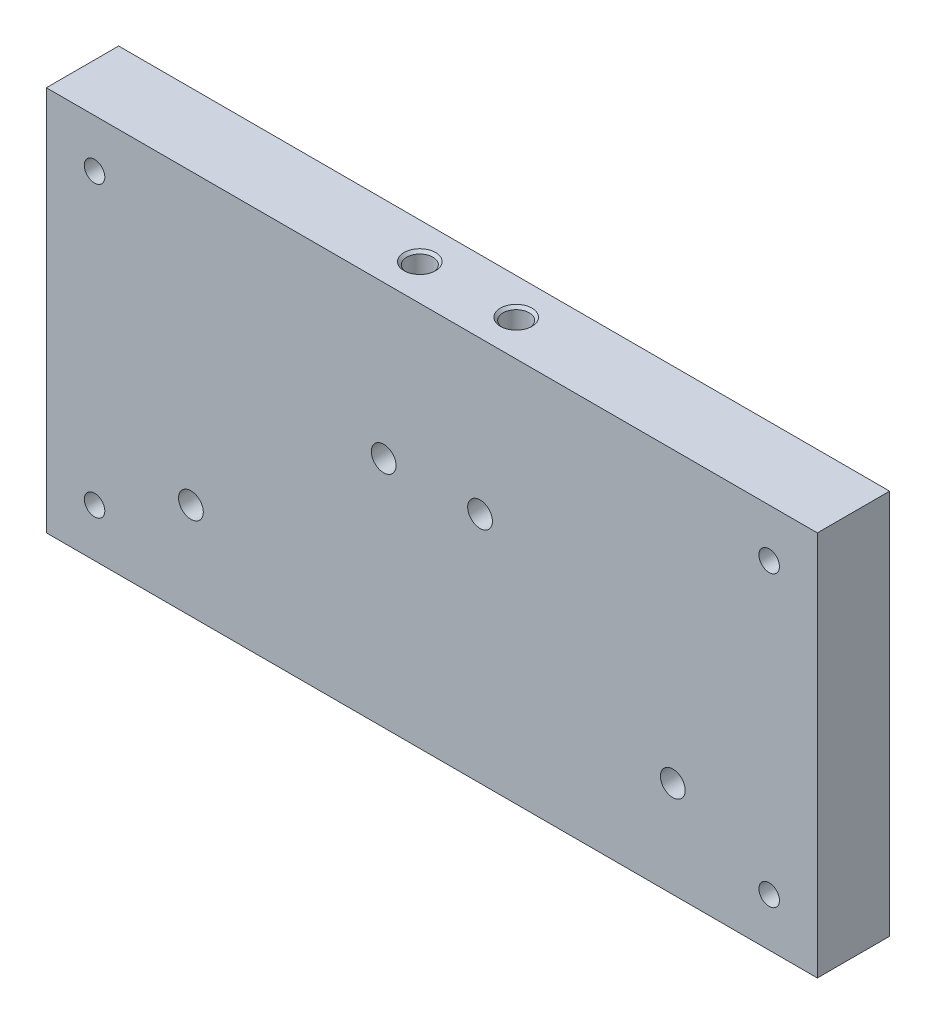
from build123d import *

# Parameters (mm, degrees)
SKETCH1_W                       = 101.6
SKETCH1_H                       = 50.8
BOSS_EXTRUDE1_DEPTH             = 9.525
F_8_32_TAPPED_HOLE1_D           = 3.4544
F_8_32_TAPPED_HOLE1_DEPTH       = 19.05
F_8_32_TAPPED_HOLE1_CSINK_D     = 4.1656
F_8_32_TAPPED_HOLE1_CSINK_ANGLE = 90
F_8_32_TAPPED_HOLE1_TIP         = 1.037806461
F_4_CLEARANCE_HOLE2_D           = 3.2639
F_4_CLEARANCE_HOLE2_DEPTH       = 25.4
F_4_CLEARANCE_HOLE2_TIP         = 0.980574487
F_6_32_TAPPED_HOLE1_D           = 2.7051
F_4_CLEARANCE_HOLE1_D           = 3.2639
F_4_CLEARANCE_HOLE1_DEPTH       = 9.525


with BuildPart() as part:
    # Sketch1 → Boss-Extrude1 (new body)
    with BuildSketch(Plane.XY):
        with Locations((-50.8, 25.4)):
            Rectangle(SKETCH1_W, SKETCH1_H)
    extrude(amount=BOSS_EXTRUDE1_DEPTH)

    # #8-32 Tapped Hole1
    with Locations(Plane(origin=(0, 50.8, 0), x_dir=(1, 0, 0), z_dir=(0, 1, 0))):
        with Locations((-44.45, -4.7625), (-57.15, -4.7625)):
            CounterSinkHole(F_8_32_TAPPED_HOLE1_D / 2, F_8_32_TAPPED_HOLE1_CSINK_D / 2, depth=F_8_32_TAPPED_HOLE1_DEPTH, counter_sink_angle=F_8_32_TAPPED_HOLE1_CSINK_ANGLE)
            with Locations((0, 0, -(F_8_32_TAPPED_HOLE1_DEPTH + F_8_32_TAPPED_HOLE1_TIP / 2))):  # 118° drill point
                Cone(0, F_8_32_TAPPED_HOLE1_D / 2, F_8_32_TAPPED_HOLE1_TIP, mode=Mode.SUBTRACT)

    # #4 Clearance Hole2
    with Locations(Plane.XY.offset(9.525)):
        with Locations((-44.45, 30.712193539), (-57.15, 30.712193539)):
            Hole(F_4_CLEARANCE_HOLE2_D / 2, depth=F_4_CLEARANCE_HOLE2_DEPTH)
            with Locations((0, 0, -(F_4_CLEARANCE_HOLE2_DEPTH + F_4_CLEARANCE_HOLE2_TIP / 2))):  # 118° drill point
                Cone(0, F_4_CLEARANCE_HOLE2_D / 2, F_4_CLEARANCE_HOLE2_TIP, mode=Mode.SUBTRACT)

    # #6-32 Tapped Hole1 (through all)
    with Locations(Plane.XY.offset(9.525)):
        with Locations((-95.25, 6.35), (-95.25, 44.45), (-6.35, 6.35), (-6.35, 44.45)):
            Hole(F_6_32_TAPPED_HOLE1_D / 2)

    # #4 Clearance Hole1
    with Locations(Plane.XY.offset(9.525)):
        with Locations((-82.55, 12.7), (-19.05, 12.7)):
            Hole(F_4_CLEARANCE_HOLE1_D / 2, depth=F_4_CLEARANCE_HOLE1_DEPTH)


solid = part.part
